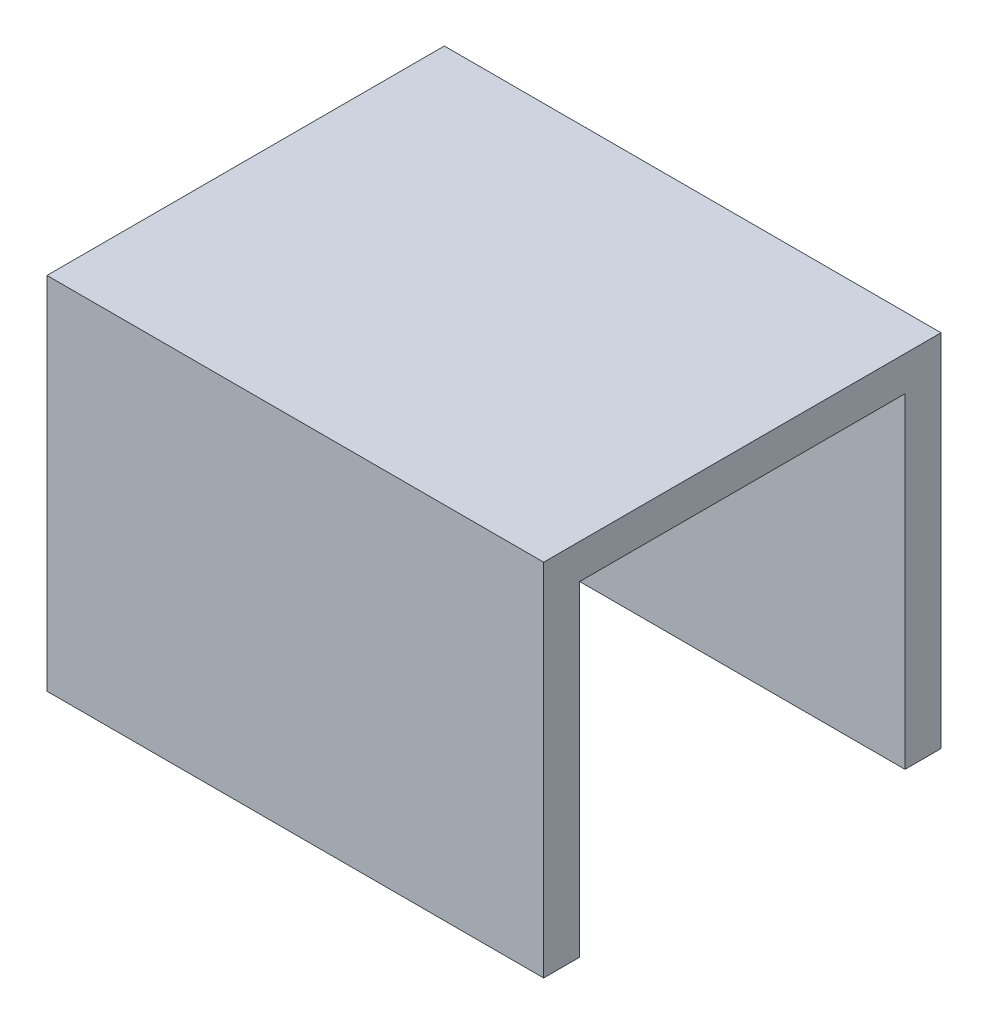
from build123d import *

# Parameters (mm, degrees)
SKETCH1_W           = 20
SKETCH1_H           = 16
BOSS_EXTRUDE1_DEPTH = 14.5
CUT_EXTRUDE1_REACH  = 22
SKETCH2_W           = 13.1
SKETCH2_H           = 13.1


with BuildPart() as part:
    # Sketch1 → Boss-Extrude1 (new body)
    with BuildSketch(Plane(origin=(0, 0, 0), x_dir=(1, 0, 0), z_dir=(0, 1, 0))):
        Rectangle(SKETCH1_W, SKETCH1_H)
    extrude(amount=BOSS_EXTRUDE1_DEPTH)

    # Sketch2 → Cut-Extrude1 (cut, up to next)
    with BuildSketch(Plane.ZY.offset(10), mode=Mode.PRIVATE) as cut_extrude1_sk1:
        with Locations((0, 6.55)):
            Rectangle(SKETCH2_W, SKETCH2_H)
    cut_extrude1_tool1 = extrude(cut_extrude1_sk1.sketch, amount=-CUT_EXTRUDE1_REACH, mode=Mode.PRIVATE) & part.part
    add(cut_extrude1_tool1.solids().sort_by_distance((-10, 6.55, 0))[0], mode=Mode.SUBTRACT)


solid = part.part
